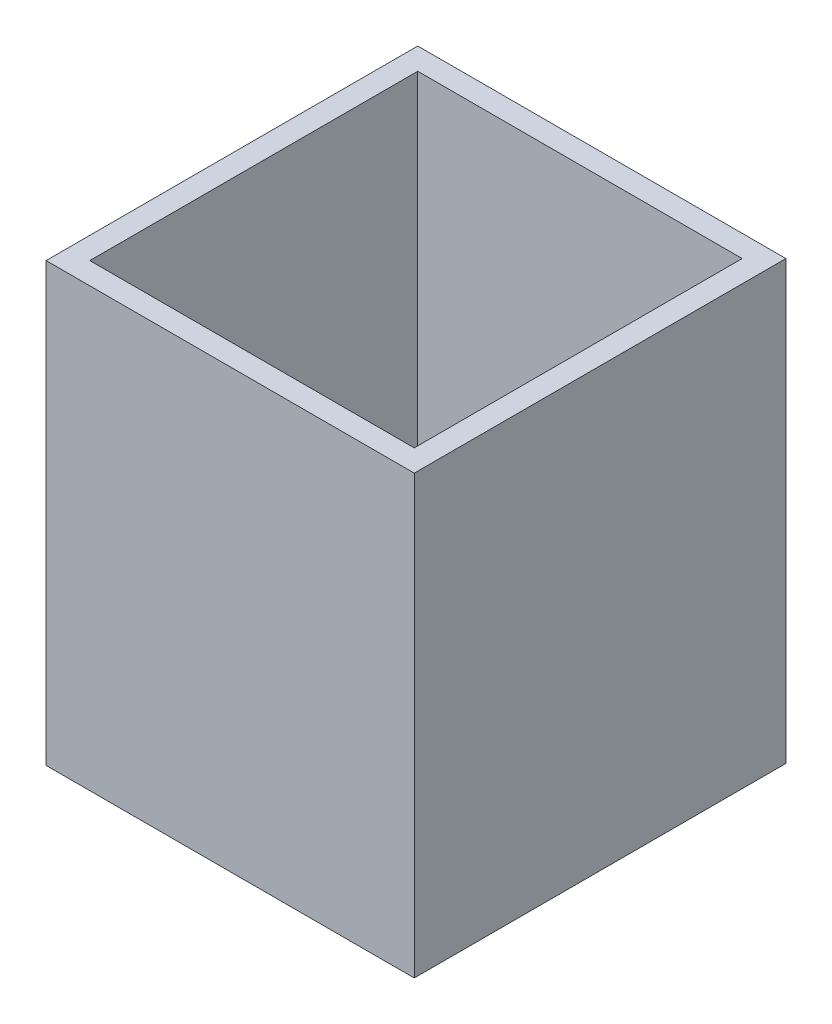
from build123d import *

# Parameters (mm, degrees)
SKETCH2_W           = 106.934
SKETCH2_H           = 107.95
BOSS_EXTRUDE1_DEPTH = 127
SHELL1_T            = -6.35


with BuildPart() as part:
    # Sketch2 → Boss-Extrude1 (new body)
    with BuildSketch(Plane(origin=(0, 0, 0), x_dir=(1, 0, 0), z_dir=(0, 1, 0))):
        Rectangle(SKETCH2_W, SKETCH2_H)
    extrude(amount=BOSS_EXTRUDE1_DEPTH)

    # Shell1
    shell1_openings = [part.faces().sort_by_distance(p)[0] for p in [
        (0, 127, 0),
        (0, 0, 0),
    ]]
    offset(amount=SHELL1_T, openings=shell1_openings, kind=Kind.INTERSECTION)


solid = part.part
